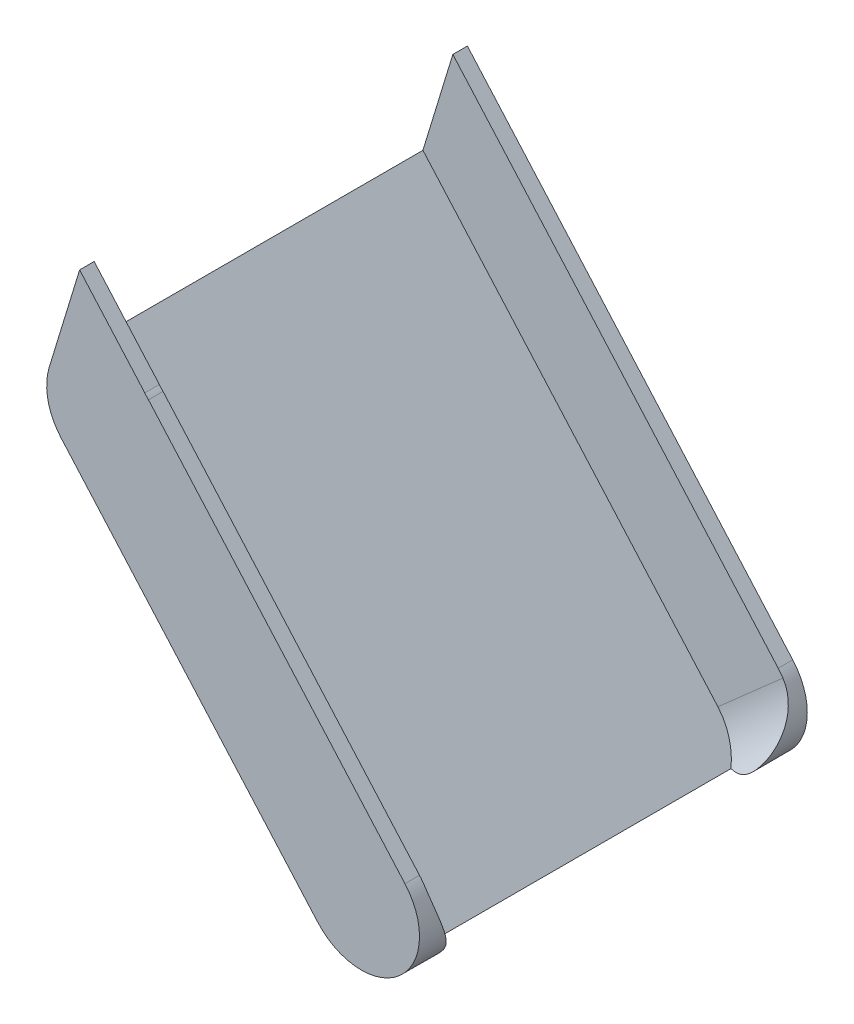
from build123d import *

# Parameters (mm, degrees)
BOSS_EXTRUDE4_DEPTH = 200
CUT_EXTRUDE5_DEPTH  = 45
BOSS_EXTRUDE5_DEPTH = 7.5
BOSS_EXTRUDE6_DEPTH = 7.5


with BuildPart() as part:
    # Sketch1 → Boss-Extrude4 (new body)
    with BuildSketch(Plane.XY):
        with BuildLine():
            Line((22.5, 19.843134833), (154.787565553, -130.156865167))
            ThreePointArc((154.787565553, -130.156865167), (152.130700386, -172.5), (109.787565553, -169.843134833))
            Line((109.787565553, -169.843134833), (-22.5, -19.843134833))
            ThreePointArc((-22.5, -19.843134833), (-19.843134833, 22.5), (22.5, 19.843134833))
        make_face()
    extrude(amount=BOSS_EXTRUDE4_DEPTH)

    # Sketch4 → Cut-Extrude5 (cut)
    with BuildSketch(Plane(origin=(22.5, 19.843134833, 0), x_dir=(0, 0, -1), z_dir=(0.75, 0.661437828, 0))):
        with BuildLine():
            Line((-192.5, 51.321419616), (-192.5, -204.008189627))
            ThreePointArc((-192.5, -204.008189627), (-182.248737342, -228.756926968), (-157.5, -239.008189627))
            Line((-157.5, -239.008189627), (-42.5, -239.008189627))
            ThreePointArc((-42.5, -239.008189627), (-17.751262658, -228.756926968), (-7.5, -204.008189627))
            Line((-7.5, -204.008189627), (-7.5, 51.321419616))
            Line((-7.5, 51.321419616), (-192.5, 51.321419616))
        make_face()
    extrude(amount=-CUT_EXTRUDE5_DEPTH, mode=Mode.SUBTRACT)

    # Sketch5 → Boss-Extrude5 (add)
    with BuildSketch(Plane(origin=(0, 0, 0), x_dir=(-1, 0, 0), z_dir=(0, 0, -1))):
        with BuildLine():
            ThreePointArc((-22.5, 19.843134833), (6.347313412, 29.320839218), (28.692196557, 8.761156129))
            Line((28.692196557, 8.761156129), (13.012632005, 60.110674556))
            Line((13.012632005, 60.110674556), (-22.5, 19.843134833))
        make_face()
    extrude(amount=-BOSS_EXTRUDE5_DEPTH)

    # Sketch6 → Boss-Extrude6 (add)
    with BuildSketch(Plane(origin=(0, 0, 192.5), x_dir=(-1, 0, 0), z_dir=(0, 0, -1))):
        Polygon((-20.631911768, 21.961347785), (13.012632005, 60.110674556), (28.692196557, 8.761156129), align=None)
    extrude(amount=-BOSS_EXTRUDE6_DEPTH)


solid = part.part
